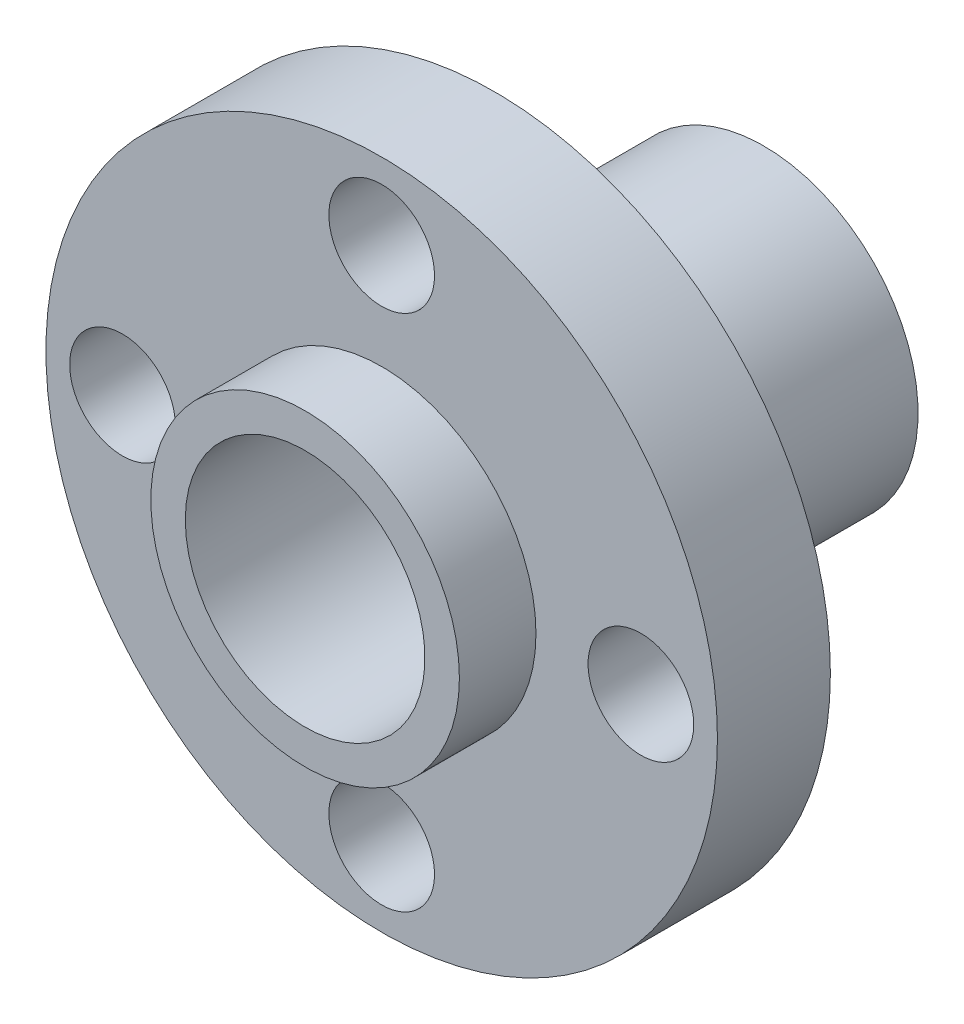
from build123d import *

# Parameters (mm, degrees)
SKETCH1_R           = 11.1379
BOSS_EXTRUDE1_DEPTH = 3.7465
SKETCH2_R           = 5.1181
BOSS_EXTRUDE2_DEPTH = 8.9281
SKETCH3_R           = 5.1181
BOSS_EXTRUDE3_DEPTH = 2.54
SKETCH4_R           = 3.9751
CUT_EXTRUDE1_DEPTH  = 16.2146
SKETCH5_R           = 1.7526
CUT_EXTRUDE2_DEPTH  = 13.6746


with BuildPart() as part:
    # Sketch1 → Boss-Extrude1 (new body)
    with BuildSketch(Plane.XY):
        Circle(SKETCH1_R)
    extrude(amount=BOSS_EXTRUDE1_DEPTH)

    # Sketch2 → Boss-Extrude2 (add)
    with BuildSketch(Plane(origin=(0, 0, 0), x_dir=(-1, 0, 0), z_dir=(0, 0, -1))):
        Circle(SKETCH2_R)
    extrude(amount=BOSS_EXTRUDE2_DEPTH)

    # Sketch3 → Boss-Extrude3 (add)
    with BuildSketch(Plane.XY.offset(3.7465)):
        Circle(SKETCH3_R)
    extrude(amount=BOSS_EXTRUDE3_DEPTH)

    # Sketch4 → Cut-Extrude1 (cut, through all)
    with BuildSketch(Plane(origin=(0, 0, -8.9281), x_dir=(-1, 0, 0), z_dir=(0, 0, -1))):
        Circle(SKETCH4_R)
    extrude(amount=-CUT_EXTRUDE1_DEPTH, mode=Mode.SUBTRACT)

    # Sketch5 → Cut-Extrude2 (cut, through all)
    with BuildSketch(Plane.XY.offset(3.7465)):
        with Locations((0, 8.5979)):
            Circle(SKETCH5_R)
        with Locations((8.5979, 0)):
            Circle(SKETCH5_R)
        with Locations((0, -8.5979)):
            Circle(SKETCH5_R)
        with Locations((-8.5979, 0)):
            Circle(SKETCH5_R)
    extrude(amount=-CUT_EXTRUDE2_DEPTH, mode=Mode.SUBTRACT)


solid = part.part
